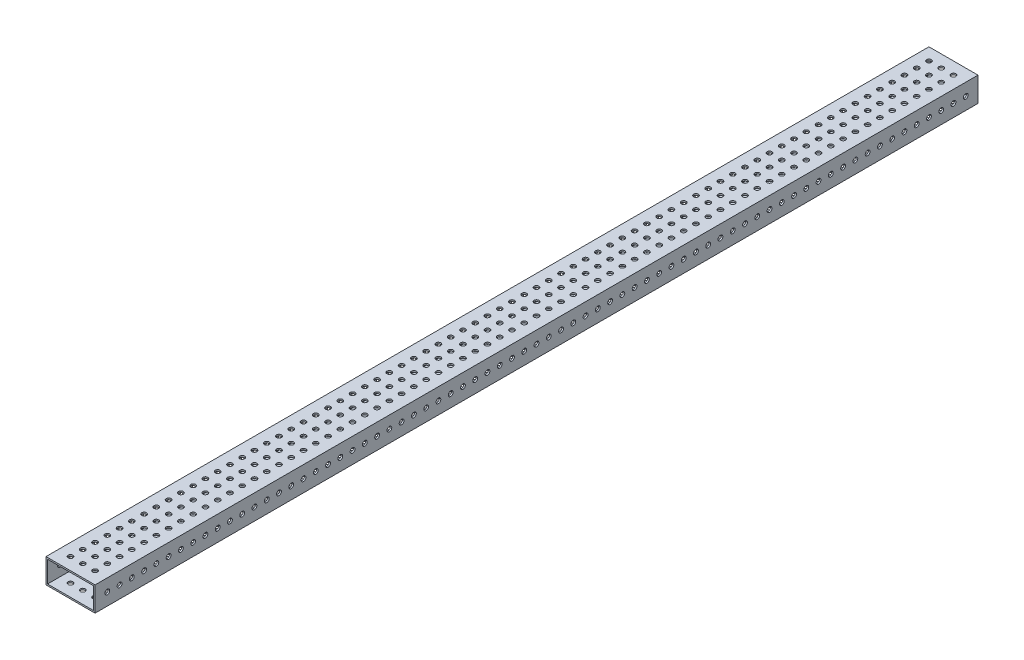
from build123d import *

# Parameters (mm, degrees)
SKETCH1_W           = 50.8
SKETCH1_H           = 25.4
SKETCH1_W_2         = 47.625
SKETCH1_H_2         = 22.225
BOSS_EXTRUDE1_DEPTH = 914.4
SKETCH2_R           = 2.4892
CUT_EXTRUDE1_DEPTH  = 51.8
SKETCH3_R           = 2.4892
CUT_EXTRUDE2_DEPTH  = 26.4


with BuildPart() as part:
    # Sketch1 → Boss-Extrude1 (new body)
    with BuildSketch(Plane.XY):
        with Locations((25.4, 12.7)):
            Rectangle(SKETCH1_W, SKETCH1_H)
        with Locations((25.4, 12.7)):
            Rectangle(SKETCH1_W_2, SKETCH1_H_2, mode=Mode.SUBTRACT)
    extrude(amount=BOSS_EXTRUDE1_DEPTH)

    # Sketch2 → Cut-Extrude1 (cut, through all)
    with BuildSketch(Plane(origin=(50.8, 0, 0), x_dir=(0, 0, -1), z_dir=(1, 0, 0))):
        with Locations((-901.7, 12.7)):
            Circle(SKETCH2_R)
        with Locations((-889, 12.7)):
            Circle(SKETCH2_R)
        with Locations((-876.3, 12.7)):
            Circle(SKETCH2_R)
        with Locations((-863.6, 12.7)):
            Circle(SKETCH2_R)
        with Locations((-850.9, 12.7)):
            Circle(SKETCH2_R)
        with Locations((-838.2, 12.7)):
            Circle(SKETCH2_R)
        with Locations((-825.5, 12.7)):
            Circle(SKETCH2_R)
        with Locations((-812.8, 12.7)):
            Circle(SKETCH2_R)
        with Locations((-800.1, 12.7)):
            Circle(SKETCH2_R)
        with Locations((-787.4, 12.7)):
            Circle(SKETCH2_R)
        with Locations((-774.7, 12.7)):
            Circle(SKETCH2_R)
        with Locations((-762, 12.7)):
            Circle(SKETCH2_R)
        with Locations((-749.3, 12.7)):
            Circle(SKETCH2_R)
        with Locations((-736.6, 12.7)):
            Circle(SKETCH2_R)
        with Locations((-723.9, 12.7)):
            Circle(SKETCH2_R)
        with Locations((-711.2, 12.7)):
            Circle(SKETCH2_R)
        with Locations((-698.5, 12.7)):
            Circle(SKETCH2_R)
        with Locations((-685.8, 12.7)):
            Circle(SKETCH2_R)
        with Locations((-673.1, 12.7)):
            Circle(SKETCH2_R)
        with Locations((-660.4, 12.7)):
            Circle(SKETCH2_R)
        with Locations((-647.7, 12.7)):
            Circle(SKETCH2_R)
        with Locations((-635, 12.7)):
            Circle(SKETCH2_R)
        with Locations((-622.3, 12.7)):
            Circle(SKETCH2_R)
        with Locations((-609.6, 12.7)):
            Circle(SKETCH2_R)
        with Locations((-596.9, 12.7)):
            Circle(SKETCH2_R)
        with Locations((-584.2, 12.7)):
            Circle(SKETCH2_R)
        with Locations((-571.5, 12.7)):
            Circle(SKETCH2_R)
        with Locations((-558.8, 12.7)):
            Circle(SKETCH2_R)
        with Locations((-546.1, 12.7)):
            Circle(SKETCH2_R)
        with Locations((-533.4, 12.7)):
            Circle(SKETCH2_R)
        with Locations((-520.7, 12.7)):
            Circle(SKETCH2_R)
        with Locations((-508, 12.7)):
            Circle(SKETCH2_R)
        with Locations((-495.3, 12.7)):
            Circle(SKETCH2_R)
        with Locations((-482.6, 12.7)):
            Circle(SKETCH2_R)
        with Locations((-469.9, 12.7)):
            Circle(SKETCH2_R)
        with Locations((-457.2, 12.7)):
            Circle(SKETCH2_R)
        with Locations((-444.5, 12.7)):
            Circle(SKETCH2_R)
        with Locations((-431.8, 12.7)):
            Circle(SKETCH2_R)
        with Locations((-419.1, 12.7)):
            Circle(SKETCH2_R)
        with Locations((-406.4, 12.7)):
            Circle(SKETCH2_R)
        with Locations((-393.7, 12.7)):
            Circle(SKETCH2_R)
        with Locations((-381, 12.7)):
            Circle(SKETCH2_R)
        with Locations((-368.3, 12.7)):
            Circle(SKETCH2_R)
        with Locations((-355.6, 12.7)):
            Circle(SKETCH2_R)
        with Locations((-342.9, 12.7)):
            Circle(SKETCH2_R)
        with Locations((-330.2, 12.7)):
            Circle(SKETCH2_R)
        with Locations((-317.5, 12.7)):
            Circle(SKETCH2_R)
        with Locations((-304.8, 12.7)):
            Circle(SKETCH2_R)
        with Locations((-292.1, 12.7)):
            Circle(SKETCH2_R)
        with Locations((-279.4, 12.7)):
            Circle(SKETCH2_R)
        with Locations((-266.7, 12.7)):
            Circle(SKETCH2_R)
        with Locations((-254, 12.7)):
            Circle(SKETCH2_R)
        with Locations((-241.3, 12.7)):
            Circle(SKETCH2_R)
        with Locations((-228.6, 12.7)):
            Circle(SKETCH2_R)
        with Locations((-215.9, 12.7)):
            Circle(SKETCH2_R)
        with Locations((-203.2, 12.7)):
            Circle(SKETCH2_R)
        with Locations((-190.5, 12.7)):
            Circle(SKETCH2_R)
        with Locations((-177.8, 12.7)):
            Circle(SKETCH2_R)
        with Locations((-165.1, 12.7)):
            Circle(SKETCH2_R)
        with Locations((-152.4, 12.7)):
            Circle(SKETCH2_R)
        with Locations((-139.7, 12.7)):
            Circle(SKETCH2_R)
        with Locations((-127, 12.7)):
            Circle(SKETCH2_R)
        with Locations((-114.3, 12.7)):
            Circle(SKETCH2_R)
        with Locations((-101.6, 12.7)):
            Circle(SKETCH2_R)
        with Locations((-88.9, 12.7)):
            Circle(SKETCH2_R)
        with Locations((-76.2, 12.7)):
            Circle(SKETCH2_R)
        with Locations((-63.5, 12.7)):
            Circle(SKETCH2_R)
        with Locations((-50.8, 12.7)):
            Circle(SKETCH2_R)
        with Locations((-38.1, 12.7)):
            Circle(SKETCH2_R)
        with Locations((-25.4, 12.7)):
            Circle(SKETCH2_R)
        with Locations((-12.7, 12.7)):
            Circle(SKETCH2_R)
    extrude(amount=-CUT_EXTRUDE1_DEPTH, mode=Mode.SUBTRACT)

    # Sketch3 → Cut-Extrude2 (cut, through all)
    with BuildSketch(Plane(origin=(0, 25.4, 0), x_dir=(1, 0, 0), z_dir=(0, 1, 0))):
        with Locations((12.7, -12.7)):
            Circle(SKETCH3_R)
        with Locations((25.4, -12.7)):
            Circle(SKETCH3_R)
        with Locations((38.1, -12.7)):
            Circle(SKETCH3_R)
        with Locations((25.4, -25.4)):
            Circle(SKETCH3_R)
        with Locations((38.1, -25.4)):
            Circle(SKETCH3_R)
        with Locations((25.4, -38.1)):
            Circle(SKETCH3_R)
        with Locations((38.1, -38.1)):
            Circle(SKETCH3_R)
        with Locations((25.4, -50.8)):
            Circle(SKETCH3_R)
        with Locations((38.1, -50.8)):
            Circle(SKETCH3_R)
        with Locations((25.4, -63.5)):
            Circle(SKETCH3_R)
        with Locations((38.1, -63.5)):
            Circle(SKETCH3_R)
        with Locations((25.4, -76.2)):
            Circle(SKETCH3_R)
        with Locations((38.1, -76.2)):
            Circle(SKETCH3_R)
        with Locations((25.4, -88.9)):
            Circle(SKETCH3_R)
        with Locations((38.1, -88.9)):
            Circle(SKETCH3_R)
        with Locations((25.4, -101.6)):
            Circle(SKETCH3_R)
        with Locations((38.1, -101.6)):
            Circle(SKETCH3_R)
        with Locations((25.4, -114.3)):
            Circle(SKETCH3_R)
        with Locations((38.1, -114.3)):
            Circle(SKETCH3_R)
        with Locations((25.4, -127)):
            Circle(SKETCH3_R)
        with Locations((38.1, -127)):
            Circle(SKETCH3_R)
        with Locations((25.4, -139.7)):
            Circle(SKETCH3_R)
        with Locations((38.1, -139.7)):
            Circle(SKETCH3_R)
        with Locations((25.4, -152.4)):
            Circle(SKETCH3_R)
        with Locations((38.1, -152.4)):
            Circle(SKETCH3_R)
        with Locations((25.4, -165.1)):
            Circle(SKETCH3_R)
        with Locations((38.1, -165.1)):
            Circle(SKETCH3_R)
        with Locations((25.4, -177.8)):
            Circle(SKETCH3_R)
        with Locations((38.1, -177.8)):
            Circle(SKETCH3_R)
        with Locations((25.4, -190.5)):
            Circle(SKETCH3_R)
        with Locations((38.1, -190.5)):
            Circle(SKETCH3_R)
        with Locations((25.4, -203.2)):
            Circle(SKETCH3_R)
        with Locations((38.1, -203.2)):
            Circle(SKETCH3_R)
        with Locations((25.4, -215.9)):
            Circle(SKETCH3_R)
        with Locations((38.1, -215.9)):
            Circle(SKETCH3_R)
        with Locations((25.4, -228.6)):
            Circle(SKETCH3_R)
        with Locations((38.1, -228.6)):
            Circle(SKETCH3_R)
        with Locations((25.4, -241.3)):
            Circle(SKETCH3_R)
        with Locations((38.1, -241.3)):
            Circle(SKETCH3_R)
        with Locations((25.4, -254)):
            Circle(SKETCH3_R)
        with Locations((38.1, -254)):
            Circle(SKETCH3_R)
        with Locations((25.4, -266.7)):
            Circle(SKETCH3_R)
        with Locations((38.1, -266.7)):
            Circle(SKETCH3_R)
        with Locations((25.4, -279.4)):
            Circle(SKETCH3_R)
        with Locations((38.1, -279.4)):
            Circle(SKETCH3_R)
        with Locations((25.4, -292.1)):
            Circle(SKETCH3_R)
        with Locations((38.1, -292.1)):
            Circle(SKETCH3_R)
        with Locations((25.4, -304.8)):
            Circle(SKETCH3_R)
        with Locations((38.1, -304.8)):
            Circle(SKETCH3_R)
        with Locations((25.4, -317.5)):
            Circle(SKETCH3_R)
        with Locations((38.1, -317.5)):
            Circle(SKETCH3_R)
        with Locations((25.4, -330.2)):
            Circle(SKETCH3_R)
        with Locations((38.1, -330.2)):
            Circle(SKETCH3_R)
        with Locations((25.4, -342.9)):
            Circle(SKETCH3_R)
        with Locations((38.1, -342.9)):
            Circle(SKETCH3_R)
        with Locations((25.4, -355.6)):
            Circle(SKETCH3_R)
        with Locations((38.1, -355.6)):
            Circle(SKETCH3_R)
        with Locations((25.4, -368.3)):
            Circle(SKETCH3_R)
        with Locations((38.1, -368.3)):
            Circle(SKETCH3_R)
        with Locations((25.4, -381)):
            Circle(SKETCH3_R)
        with Locations((38.1, -381)):
            Circle(SKETCH3_R)
        with Locations((25.4, -393.7)):
            Circle(SKETCH3_R)
        with Locations((38.1, -393.7)):
            Circle(SKETCH3_R)
        with Locations((25.4, -406.4)):
            Circle(SKETCH3_R)
        with Locations((38.1, -406.4)):
            Circle(SKETCH3_R)
        with Locations((25.4, -419.1)):
            Circle(SKETCH3_R)
        with Locations((38.1, -419.1)):
            Circle(SKETCH3_R)
        with Locations((25.4, -431.8)):
            Circle(SKETCH3_R)
        with Locations((38.1, -431.8)):
            Circle(SKETCH3_R)
        with Locations((25.4, -444.5)):
            Circle(SKETCH3_R)
        with Locations((38.1, -444.5)):
            Circle(SKETCH3_R)
        with Locations((25.4, -457.2)):
            Circle(SKETCH3_R)
        with Locations((38.1, -457.2)):
            Circle(SKETCH3_R)
        with Locations((25.4, -469.9)):
            Circle(SKETCH3_R)
        with Locations((38.1, -469.9)):
            Circle(SKETCH3_R)
        with Locations((25.4, -482.6)):
            Circle(SKETCH3_R)
        with Locations((38.1, -482.6)):
            Circle(SKETCH3_R)
        with Locations((25.4, -495.3)):
            Circle(SKETCH3_R)
        with Locations((38.1, -495.3)):
            Circle(SKETCH3_R)
        with Locations((25.4, -508)):
            Circle(SKETCH3_R)
        with Locations((38.1, -508)):
            Circle(SKETCH3_R)
        with Locations((25.4, -520.7)):
            Circle(SKETCH3_R)
        with Locations((38.1, -520.7)):
            Circle(SKETCH3_R)
        with Locations((25.4, -533.4)):
            Circle(SKETCH3_R)
        with Locations((38.1, -533.4)):
            Circle(SKETCH3_R)
        with Locations((25.4, -546.1)):
            Circle(SKETCH3_R)
        with Locations((38.1, -546.1)):
            Circle(SKETCH3_R)
        with Locations((25.4, -558.8)):
            Circle(SKETCH3_R)
        with Locations((38.1, -558.8)):
            Circle(SKETCH3_R)
        with Locations((25.4, -571.5)):
            Circle(SKETCH3_R)
        with Locations((38.1, -571.5)):
            Circle(SKETCH3_R)
        with Locations((25.4, -584.2)):
            Circle(SKETCH3_R)
        with Locations((38.1, -584.2)):
            Circle(SKETCH3_R)
        with Locations((25.4, -596.9)):
            Circle(SKETCH3_R)
        with Locations((38.1, -596.9)):
            Circle(SKETCH3_R)
        with Locations((25.4, -609.6)):
            Circle(SKETCH3_R)
        with Locations((38.1, -609.6)):
            Circle(SKETCH3_R)
        with Locations((25.4, -622.3)):
            Circle(SKETCH3_R)
        with Locations((38.1, -622.3)):
            Circle(SKETCH3_R)
        with Locations((25.4, -635)):
            Circle(SKETCH3_R)
        with Locations((38.1, -635)):
            Circle(SKETCH3_R)
        with Locations((25.4, -647.7)):
            Circle(SKETCH3_R)
        with Locations((38.1, -647.7)):
            Circle(SKETCH3_R)
        with Locations((25.4, -660.4)):
            Circle(SKETCH3_R)
        with Locations((38.1, -660.4)):
            Circle(SKETCH3_R)
        with Locations((25.4, -673.1)):
            Circle(SKETCH3_R)
        with Locations((38.1, -673.1)):
            Circle(SKETCH3_R)
        with Locations((25.4, -685.8)):
            Circle(SKETCH3_R)
        with Locations((38.1, -685.8)):
            Circle(SKETCH3_R)
        with Locations((25.4, -698.5)):
            Circle(SKETCH3_R)
        with Locations((38.1, -698.5)):
            Circle(SKETCH3_R)
        with Locations((25.4, -711.2)):
            Circle(SKETCH3_R)
        with Locations((38.1, -711.2)):
            Circle(SKETCH3_R)
        with Locations((25.4, -723.9)):
            Circle(SKETCH3_R)
        with Locations((38.1, -723.9)):
            Circle(SKETCH3_R)
        with Locations((25.4, -736.6)):
            Circle(SKETCH3_R)
        with Locations((38.1, -736.6)):
            Circle(SKETCH3_R)
        with Locations((25.4, -749.3)):
            Circle(SKETCH3_R)
        with Locations((38.1, -749.3)):
            Circle(SKETCH3_R)
        with Locations((25.4, -762)):
            Circle(SKETCH3_R)
        with Locations((38.1, -762)):
            Circle(SKETCH3_R)
        with Locations((25.4, -774.7)):
            Circle(SKETCH3_R)
        with Locations((38.1, -774.7)):
            Circle(SKETCH3_R)
        with Locations((25.4, -787.4)):
            Circle(SKETCH3_R)
        with Locations((38.1, -787.4)):
            Circle(SKETCH3_R)
        with Locations((25.4, -800.1)):
            Circle(SKETCH3_R)
        with Locations((38.1, -800.1)):
            Circle(SKETCH3_R)
        with Locations((25.4, -812.8)):
            Circle(SKETCH3_R)
        with Locations((38.1, -812.8)):
            Circle(SKETCH3_R)
        with Locations((25.4, -825.5)):
            Circle(SKETCH3_R)
        with Locations((38.1, -825.5)):
            Circle(SKETCH3_R)
        with Locations((25.4, -838.2)):
            Circle(SKETCH3_R)
        with Locations((38.1, -838.2)):
            Circle(SKETCH3_R)
        with Locations((25.4, -850.9)):
            Circle(SKETCH3_R)
        with Locations((38.1, -850.9)):
            Circle(SKETCH3_R)
        with Locations((25.4, -863.6)):
            Circle(SKETCH3_R)
        with Locations((38.1, -863.6)):
            Circle(SKETCH3_R)
        with Locations((25.4, -876.3)):
            Circle(SKETCH3_R)
        with Locations((38.1, -876.3)):
            Circle(SKETCH3_R)
        with Locations((25.4, -889)):
            Circle(SKETCH3_R)
        with Locations((38.1, -889)):
            Circle(SKETCH3_R)
        with Locations((25.4, -901.7)):
            Circle(SKETCH3_R)
        with Locations((38.1, -901.7)):
            Circle(SKETCH3_R)
        with Locations((12.7, -25.4)):
            Circle(SKETCH3_R)
        with Locations((12.7, -38.1)):
            Circle(SKETCH3_R)
        with Locations((12.7, -50.8)):
            Circle(SKETCH3_R)
        with Locations((12.7, -63.5)):
            Circle(SKETCH3_R)
        with Locations((12.7, -76.2)):
            Circle(SKETCH3_R)
        with Locations((12.7, -88.9)):
            Circle(SKETCH3_R)
        with Locations((12.7, -101.6)):
            Circle(SKETCH3_R)
        with Locations((12.7, -114.3)):
            Circle(SKETCH3_R)
        with Locations((12.7, -127)):
            Circle(SKETCH3_R)
        with Locations((12.7, -139.7)):
            Circle(SKETCH3_R)
        with Locations((12.7, -152.4)):
            Circle(SKETCH3_R)
        with Locations((12.7, -165.1)):
            Circle(SKETCH3_R)
        with Locations((12.7, -177.8)):
            Circle(SKETCH3_R)
        with Locations((12.7, -190.5)):
            Circle(SKETCH3_R)
        with Locations((12.7, -203.2)):
            Circle(SKETCH3_R)
        with Locations((12.7, -215.9)):
            Circle(SKETCH3_R)
        with Locations((12.7, -228.6)):
            Circle(SKETCH3_R)
        with Locations((12.7, -241.3)):
            Circle(SKETCH3_R)
        with Locations((12.7, -254)):
            Circle(SKETCH3_R)
        with Locations((12.7, -266.7)):
            Circle(SKETCH3_R)
        with Locations((12.7, -279.4)):
            Circle(SKETCH3_R)
        with Locations((12.7, -292.1)):
            Circle(SKETCH3_R)
        with Locations((12.7, -304.8)):
            Circle(SKETCH3_R)
        with Locations((12.7, -317.5)):
            Circle(SKETCH3_R)
        with Locations((12.7, -330.2)):
            Circle(SKETCH3_R)
        with Locations((12.7, -342.9)):
            Circle(SKETCH3_R)
        with Locations((12.7, -355.6)):
            Circle(SKETCH3_R)
        with Locations((12.7, -368.3)):
            Circle(SKETCH3_R)
        with Locations((12.7, -381)):
            Circle(SKETCH3_R)
        with Locations((12.7, -393.7)):
            Circle(SKETCH3_R)
        with Locations((12.7, -406.4)):
            Circle(SKETCH3_R)
        with Locations((12.7, -419.1)):
            Circle(SKETCH3_R)
        with Locations((12.7, -431.8)):
            Circle(SKETCH3_R)
        with Locations((12.7, -444.5)):
            Circle(SKETCH3_R)
        with Locations((12.7, -457.2)):
            Circle(SKETCH3_R)
        with Locations((12.7, -469.9)):
            Circle(SKETCH3_R)
        with Locations((12.7, -482.6)):
            Circle(SKETCH3_R)
        with Locations((12.7, -495.3)):
            Circle(SKETCH3_R)
        with Locations((12.7, -508)):
            Circle(SKETCH3_R)
        with Locations((12.7, -520.7)):
            Circle(SKETCH3_R)
        with Locations((12.7, -533.4)):
            Circle(SKETCH3_R)
        with Locations((12.7, -546.1)):
            Circle(SKETCH3_R)
        with Locations((12.7, -558.8)):
            Circle(SKETCH3_R)
        with Locations((12.7, -571.5)):
            Circle(SKETCH3_R)
        with Locations((12.7, -584.2)):
            Circle(SKETCH3_R)
        with Locations((12.7, -596.9)):
            Circle(SKETCH3_R)
        with Locations((12.7, -609.6)):
            Circle(SKETCH3_R)
        with Locations((12.7, -622.3)):
            Circle(SKETCH3_R)
        with Locations((12.7, -635)):
            Circle(SKETCH3_R)
        with Locations((12.7, -647.7)):
            Circle(SKETCH3_R)
        with Locations((12.7, -660.4)):
            Circle(SKETCH3_R)
        with Locations((12.7, -673.1)):
            Circle(SKETCH3_R)
        with Locations((12.7, -685.8)):
            Circle(SKETCH3_R)
        with Locations((12.7, -698.5)):
            Circle(SKETCH3_R)
        with Locations((12.7, -711.2)):
            Circle(SKETCH3_R)
        with Locations((12.7, -723.9)):
            Circle(SKETCH3_R)
        with Locations((12.7, -736.6)):
            Circle(SKETCH3_R)
        with Locations((12.7, -749.3)):
            Circle(SKETCH3_R)
        with Locations((12.7, -762)):
            Circle(SKETCH3_R)
        with Locations((12.7, -774.7)):
            Circle(SKETCH3_R)
        with Locations((12.7, -787.4)):
            Circle(SKETCH3_R)
        with Locations((12.7, -800.1)):
            Circle(SKETCH3_R)
        with Locations((12.7, -812.8)):
            Circle(SKETCH3_R)
        with Locations((12.7, -825.5)):
            Circle(SKETCH3_R)
        with Locations((12.7, -838.2)):
            Circle(SKETCH3_R)
        with Locations((12.7, -850.9)):
            Circle(SKETCH3_R)
        with Locations((12.7, -863.6)):
            Circle(SKETCH3_R)
        with Locations((12.7, -876.3)):
            Circle(SKETCH3_R)
        with Locations((12.7, -889)):
            Circle(SKETCH3_R)
        with Locations((12.7, -901.7)):
            Circle(SKETCH3_R)
    extrude(amount=-CUT_EXTRUDE2_DEPTH, mode=Mode.SUBTRACT)


solid = part.part
